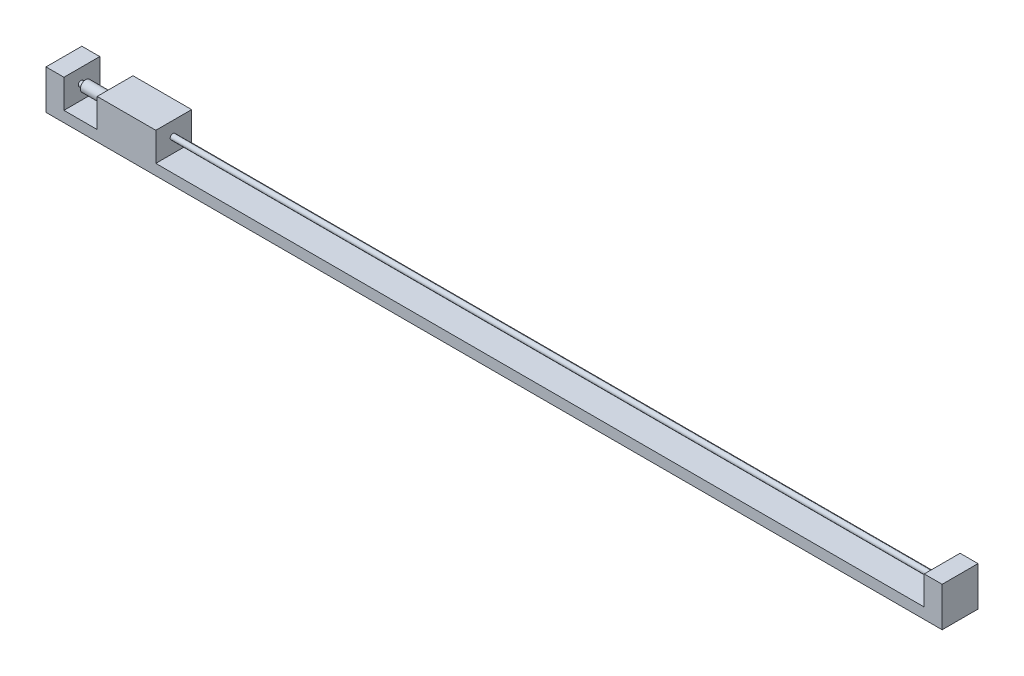
from build123d import *

# Parameters (mm, degrees)
SKETCH2_W           = 250
SKETCH2_H           = 10
BOSS_EXTRUDE1_DEPTH = 3
SKETCH3_W           = 5
SKETCH3_H           = 10
BOSS_EXTRUDE2_DEPTH = 8
BOSS_EXTRUDE3_REACH = 247
SKETCH4_R           = 0.75
SKETCH5_W           = 16.35970525
SKETCH5_H           = 10
BOSS_EXTRUDE4_DEPTH = 8
SKETCH6_R           = 1.4956439
SKETCH6_R_2         = 1.153364649
BOSS_EXTRUDE5_DEPTH = 8


with BuildPart() as part:
    # Sketch2 → Boss-Extrude1 (new body)
    with BuildSketch(Plane(origin=(0, 0, 0), x_dir=(1, 0, 0), z_dir=(0, 1, 0))):
        with Locations((125, 5)):
            Rectangle(SKETCH2_W, SKETCH2_H)
    extrude(amount=BOSS_EXTRUDE1_DEPTH)

    # Sketch3 → Boss-Extrude2 (add)
    with BuildSketch(Plane(origin=(0, 3, 0), x_dir=(1, 0, 0), z_dir=(0, 1, 0))):
        with Locations((2.5, 5)):
            Rectangle(SKETCH3_W, SKETCH3_H)
        with Locations((247.5, 5)):
            Rectangle(SKETCH3_W, SKETCH3_H)
    extrude(amount=BOSS_EXTRUDE2_DEPTH)

    # Sketch4 → Boss-Extrude3 (add, up to next)
    with BuildSketch(Plane(origin=(5, 0, 0), x_dir=(0, 0, -1), z_dir=(1, 0, 0)), mode=Mode.PRIVATE) as boss_extrude3_sk1:
        with Locations((4.754905599, 7.100772806)):
            Circle(SKETCH4_R)
    boss_extrude3_tool1 = extrude(boss_extrude3_sk1.sketch, amount=BOSS_EXTRUDE3_REACH, mode=Mode.PRIVATE) - part.part
    add(boss_extrude3_tool1.solids().sort_by_distance((5, 7.100773, -4.754906))[0])

    # Sketch5 → Boss-Extrude4 (add)
    with BuildSketch(Plane(origin=(0, 3, 0), x_dir=(1, 0, 0), z_dir=(0, 1, 0))):
        with Locations((22.45057465, 5)):
            Rectangle(SKETCH5_W, SKETCH5_H)
    extrude(amount=BOSS_EXTRUDE4_DEPTH)

    # Sketch6 → Boss-Extrude5 (add)
    with BuildSketch(Plane.ZY.offset(-14.270722025)):
        with Locations((-4.800860799, 7.162046407)):
            Circle(SKETCH6_R)
        with Locations((-4.800860799, 7.162046407)):
            Circle(SKETCH6_R_2, mode=Mode.SUBTRACT)
    extrude(amount=BOSS_EXTRUDE5_DEPTH)


solid = part.part
